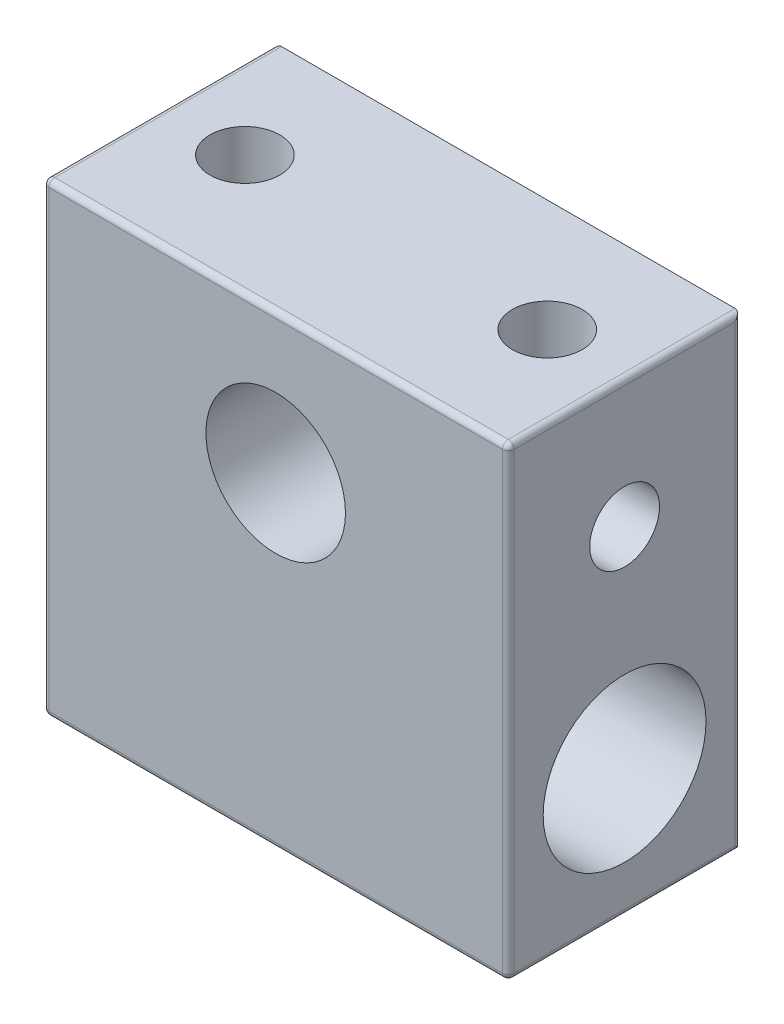
from build123d import *

# Parameters (mm, degrees)
SKETCH1_W           = 20
SKETCH1_H           = 20
BOSS_EXTRUDE1_DEPTH = 10
FILLET1_R           = 0.25
SKETCH2_R           = 3
CUT_EXTRUDE1_DEPTH  = 10
SKETCH3_R           = 3.5
CUT_EXTRUDE2_DEPTH  = 20
SKETCH4_R           = 1.5
CUT_EXTRUDE3_DEPTH  = 6.5
SKETCH5_R           = 1.5
CUT_EXTRUDE4_DEPTH  = 6.5
SKETCH6_R           = 1.5
CUT_EXTRUDE5_DEPTH  = 6


with BuildPart() as part:
    # Sketch1 → Boss-Extrude1 (new body)
    with BuildSketch(Plane.XY):
        Rectangle(SKETCH1_W, SKETCH1_H)
    extrude(amount=BOSS_EXTRUDE1_DEPTH)

    # Fillet1
    fillet1_edges = [part.edges().sort_by_distance(p)[0] for p in [
        (-10, 0, 10),
        (0, -10, 10),
        (10, 0, 10),
        (-10, 0, 0),
        (10, 0, 0),
        (0, 10, 10),
        (10, -10, 5),
        (-10, -10, 5),
        (-10, 10, 5),
        (10, 10, 5),
    ]]
    fillet(fillet1_edges, radius=FILLET1_R)

    # Sketch2 → Cut-Extrude1 (cut)
    with BuildSketch(Plane.XY.offset(10)):
        with Locations((0, 4)):
            Circle(SKETCH2_R)
    extrude(amount=-CUT_EXTRUDE1_DEPTH, mode=Mode.SUBTRACT)

    # Sketch3 → Cut-Extrude2 (cut)
    with BuildSketch(Plane.ZY.offset(10)):
        with Locations((5, -4.5)):
            Circle(SKETCH3_R)
    extrude(amount=-CUT_EXTRUDE2_DEPTH, mode=Mode.SUBTRACT)

    # Sketch4 → Cut-Extrude3 (cut)
    with BuildSketch(Plane.ZY.offset(10)):
        with Locations((5, 4.5)):
            Circle(SKETCH4_R)
    extrude(amount=-CUT_EXTRUDE3_DEPTH, mode=Mode.SUBTRACT)

    # Sketch5 → Cut-Extrude4 (cut)
    with BuildSketch(Plane(origin=(10, 0, 0), x_dir=(0, 0, -1), z_dir=(1, 0, 0))):
        with Locations((-5, 4.5)):
            Circle(SKETCH5_R)
    extrude(amount=-CUT_EXTRUDE4_DEPTH, mode=Mode.SUBTRACT)

    # Sketch6 → Cut-Extrude5 (cut)
    with BuildSketch(Plane(origin=(0, 10, 0), x_dir=(1, 0, 0), z_dir=(0, 1, 0))):
        with Locations((-6.5, -4.824104789)):
            Circle(SKETCH6_R)
        with Locations((6.5, -4.824104789)):
            Circle(SKETCH6_R)
    extrude(amount=-CUT_EXTRUDE5_DEPTH, mode=Mode.SUBTRACT)


solid = part.part
